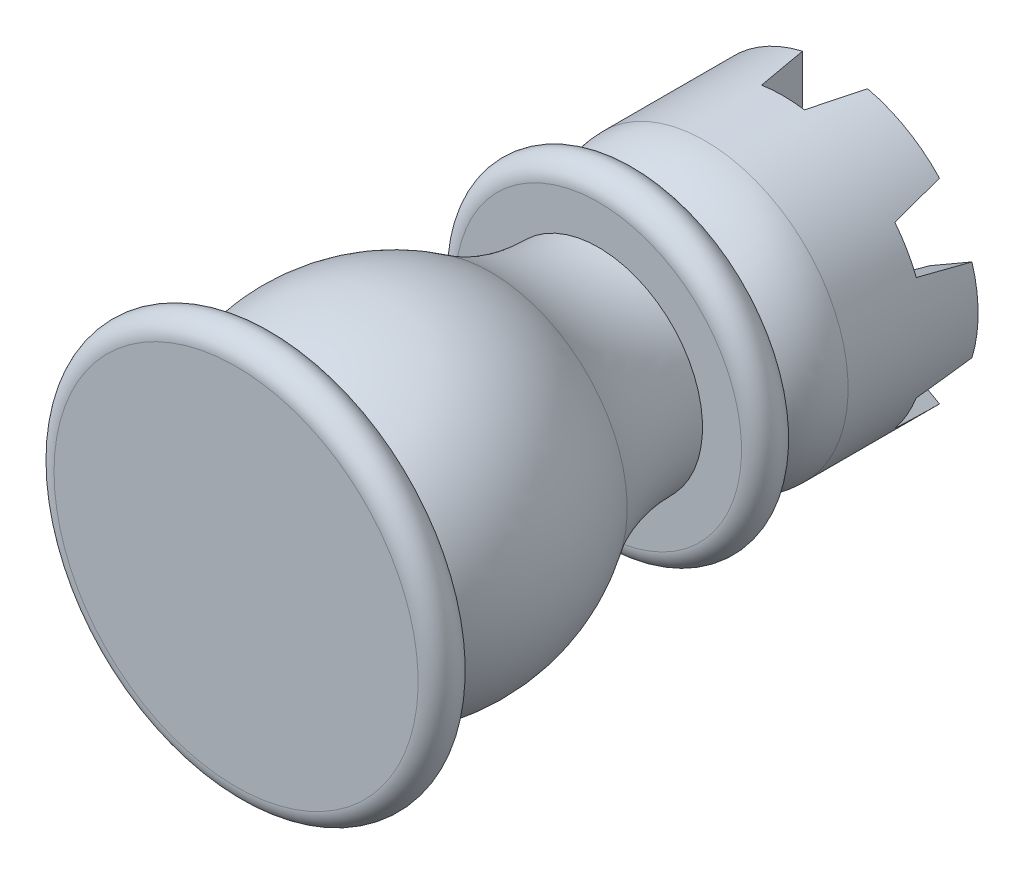
from build123d import *

# Parameters (mm, degrees)
SKETCH5_R           = 11
BOSS_EXTRUDE1_DEPTH = 8
CUT_EXTRUDE1_DEPTH  = 16.5000001
CIRPATTERN1_COUNT   = 3


with BuildPart() as part:
    # Sketch1 → Revolve2 (revolve)
    with BuildSketch(Plane(origin=(0, 0, 0), x_dir=(1, 0, 0), z_dir=(0, 1, 0))):
        with BuildLine():
            ThreePointArc((-11.874240636, -1.5), (-13.259434586, -0.119297362), (-14.45321304, 1.429894381))
            ThreePointArc((-14.45321304, 1.429894381), (-15.482369989, -0.22930158), (-14, -1.5))
            Line((-14, -1.5), (-11.874240636, -1.5))
        make_face()
        with BuildLine():
            Line((-10.5, 1.5), (-14, 1.5))
            ThreePointArc((-14, 1.5), (-14.22930158, 1.482369989), (-14.45321304, 1.429894381))
            ThreePointArc((-14.45321304, 1.429894381), (-13.259434586, -0.119297362), (-11.874240636, -1.5))
            Line((-11.874240636, -1.5), (-7.874240636, -1.5))
            ThreePointArc((-7.874240636, -1.5), (-9.287234427, -0.087625186), (-10.5, 1.5))
        make_face()
        with BuildLine():
            Line((0, 1.5), (-10.5, 1.5))
            ThreePointArc((-10.5, 1.5), (-9.287234427, -0.087625186), (-7.874240636, -1.5))
            Line((-7.874240636, -1.5), (0, -1.5))
            Line((0, -1.5), (0, 0))
            Line((0, 0), (0, 1.5))
        make_face()
        with BuildLine():
            ThreePointArc((-10.499999775, 18.083124291), (-13, 9.79156218), (-10.5, 1.5))
            Line((-10.5, 1.5), (0, 1.5))
            Line((0, 1.5), (0, 24.657630723))
            ThreePointArc((0, 24.657630723), (-5.96043542, 22.504998487), (-10.499999775, 18.083124291))
        make_face()
        with BuildLine():
            ThreePointArc((-8.296715836, 23.405942964), (-9.140426773, 20.63776777), (-10.499999775, 18.083124291))
            ThreePointArc((-10.499999775, 18.083124291), (-5.96043542, 22.504998487), (0, 24.657630723))
            ThreePointArc((0, 24.657630723), (-4.237660007, 24.623718855), (-8.296715836, 23.405942964))
        make_face()
        with BuildLine():
            ThreePointArc((-8, 26.374685928), (-8.074363289, 24.882918932), (-8.296715836, 23.405942964))
            ThreePointArc((-8.296715836, 23.405942964), (-4.237660007, 24.623718855), (0, 24.657630723))
            Line((0, 24.657630723), (0, 26.374685928))
            Line((0, 26.374685928), (-8, 26.374685928))
        make_face()
        with BuildLine():
            Line((-11, 26.374685928), (-8, 26.374685928))
            Line((-8, 26.374685928), (0, 26.374685928))
            Line((0, 26.374685928), (0, 29.374685928))
            Line((0, 29.374685928), (-8, 29.374685928))
            Line((-8, 29.374685928), (-11, 29.374685928))
            ThreePointArc((-11, 29.374685928), (-12.5, 27.874685928), (-11, 26.374685928))
        make_face()
        with BuildLine():
            Line((-8, 29.374685928), (0, 29.374685928))
            Line((0, 29.374685928), (0, 36.57083835))
            Line((0, 36.57083835), (-11, 36.57083835))
            Line((-11, 36.57083835), (-11, 34.57083835))
            ThreePointArc((-11, 34.57083835), (-10.196152423, 31.57083835), (-8, 29.374685928))
        make_face()
    revolve(axis=Axis((0, 0, -36.57083835), (0, 0, 1)))

    # Sketch5 → Boss-Extrude1 (add)
    with BuildSketch(Plane(origin=(0, 0, -36.57083835), x_dir=(-1, 0, 0), z_dir=(0, 0, -1))):
        Circle(SKETCH5_R)
    extrude(amount=BOSS_EXTRUDE1_DEPTH)

    # Sketch6 → Cut-Extrude1 (cut, symmetric)
    with BuildSketch(Plane(origin=(0, 0, 0), x_dir=(1, 0, 0), z_dir=(0, 1, 0))):
        Polygon((-2.5, 44.57083835), (2.5, 44.57083835), (1.649773753, 40.57083835), (-1.649773753, 40.57083835), align=None)
    cut_extrude1 = extrude(amount=CUT_EXTRUDE1_DEPTH, both=True, mode=Mode.SUBTRACT)

    # CirPattern1: Cut-Extrude1 ×3 about axis
    cirpattern1_axis = Axis((0, 0, 0), (0, 0, 1))
    for i in range(1, CIRPATTERN1_COUNT):
        add(cut_extrude1.rotate(cirpattern1_axis, i * 360 / CIRPATTERN1_COUNT), mode=Mode.SUBTRACT)

    # Sketch7 → Cut-Revolve1 (revolve, cut)
    with BuildSketch(Plane(origin=(0, 0, 0), x_dir=(1, 0, 0), z_dir=(0, 1, 0))):
        Polygon((0, 36.57083835), (6, 36.57083835), (9.549821519, 56.702876593), (0, 56.702876593), align=None)
    revolve(axis=Axis((0, 0, -40.57083835), (0, 0, 1)), mode=Mode.SUBTRACT)


solid = part.part
